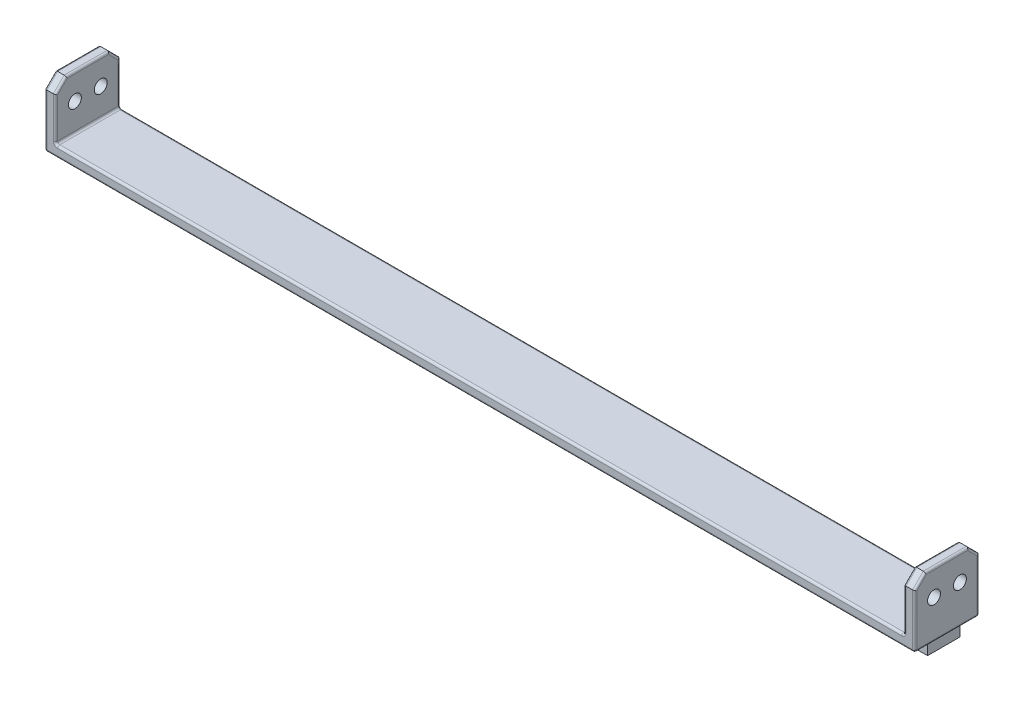
from build123d import *

# Parameters (mm, degrees)
EXTRUDE_THIN1_DEPTH   = 30
CHAMFER1_SIZE         = 5
FILLET1_R             = 1
F_6_0MM_DOWEL_SLOT1_D = 6
SKETCH6_W             = 401.86
SKETCH6_H             = 15
BOSS_EXTRUDE1_DEPTH   = 5


with BuildPart() as part:
    # Sketch1 → Extrude-Thin1 (new body)
    with BuildSketch(Plane.XY):
        Polygon((-201.93, 30), (-201.93, 0), (201.93, 0), (201.93, 30), (196.93, 30), (196.93, 5), (-196.93, 5), (-196.93, 30), align=None)
    extrude(amount=-EXTRUDE_THIN1_DEPTH)

    # Chamfer1
    chamfer1_edges = [part.edges().sort_by_distance(p)[0] for p in [
        (-199.43, 30, -30),
        (-199.43, 30, 0),
        (199.43, 30, -30),
        (199.43, 30, 0),
    ]]
    chamfer(chamfer1_edges, length=CHAMFER1_SIZE)

    # Fillet1
    fillet1_edges = [part.edges().sort_by_distance(p)[0] for p in [
        (201.93, 0, -15),
        (-201.93, 0, -15),
        (-196.93, 5, -15),
        (196.93, 5, -15),
        (196.93, 15, -30),
        (0, 5, -30),
        (-201.93, 12.5, -30),
        (-196.93, 15, -30),
        (201.93, 30, -15),
        (201.93, 27.5, -2.5),
        (201.93, 27.5, -27.5),
        (196.93, 30, -15),
        (196.93, 27.5, -2.5),
        (196.93, 27.5, -27.5),
        (-196.93, 15, 0),
        (-201.93, 12.5, 0),
        (0, 0, -30),
        (-196.93, 30, -15),
        (-196.93, 27.5, -2.5),
        (-196.93, 27.5, -27.5),
        (-201.93, 30, -15),
        (-201.93, 27.5, -2.5),
        (-201.93, 27.5, -27.5),
        (201.93, 12.5, -30),
        (0, 0, 0),
        (0, 5, 0),
        (196.93, 15, 0),
        (201.93, 12.5, 0),
    ]]
    fillet(fillet1_edges, radius=FILLET1_R)

    # Ø6.0mm Dowel Slot1 (through all)
    with Locations(Plane(origin=(201.93, 0, 0), x_dir=(0, 0, -1), z_dir=(1, 0, 0))):
        with Locations((21, 18), (9, 18)):
            Hole(F_6_0MM_DOWEL_SLOT1_D / 2)


with BuildPart() as body_2:
    # Sketch6 → Boss-Extrude1 (new body)
    with BuildSketch(Plane.XZ):
        with Locations((0, -14.5)):
            Rectangle(SKETCH6_W, SKETCH6_H)
    extrude(amount=BOSS_EXTRUDE1_DEPTH)


solid = Compound([part.part, body_2.part])
